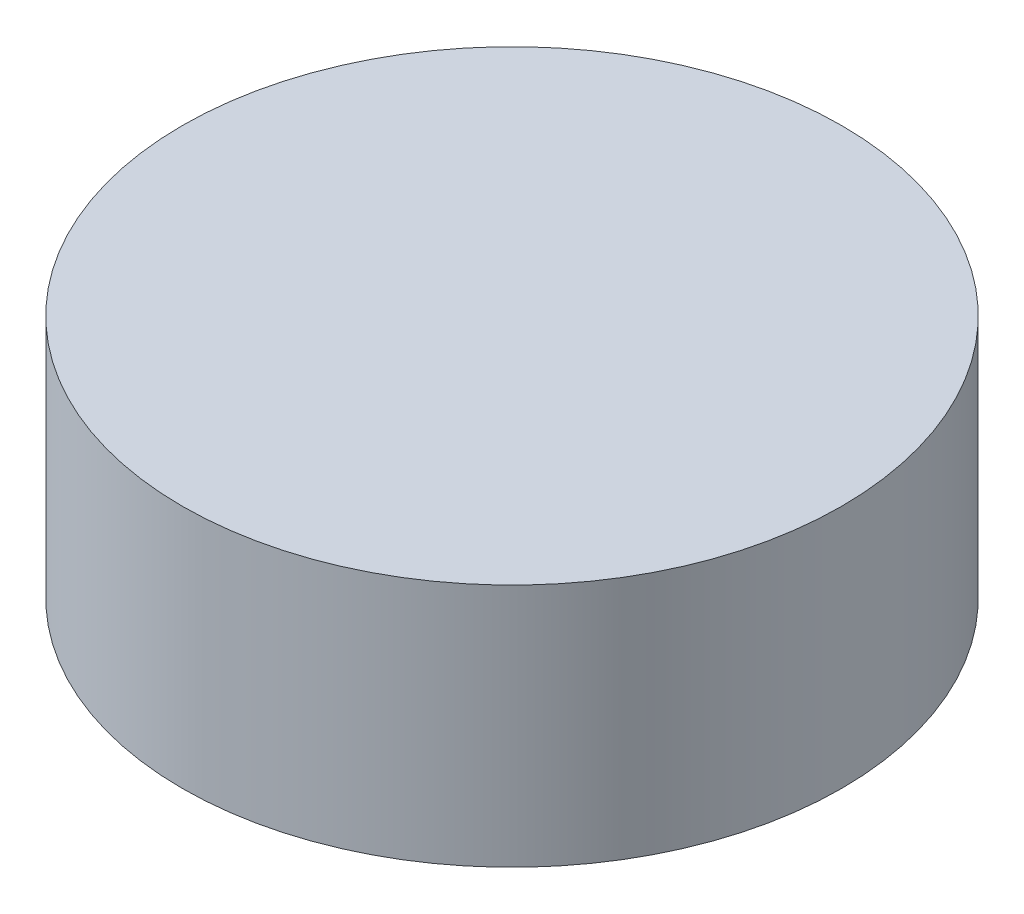
from build123d import *

# Parameters (mm, degrees)
SKETCH1_R           = 13.49
BOSS_EXTRUDE1_DEPTH = 10


with BuildPart() as part:
    # Sketch1 → Boss-Extrude1 (new body)
    with BuildSketch(Plane(origin=(0, 0, 0), x_dir=(1, 0, 0), z_dir=(0, 1, 0))):
        Circle(SKETCH1_R)
    extrude(amount=BOSS_EXTRUDE1_DEPTH)


solid = part.part
